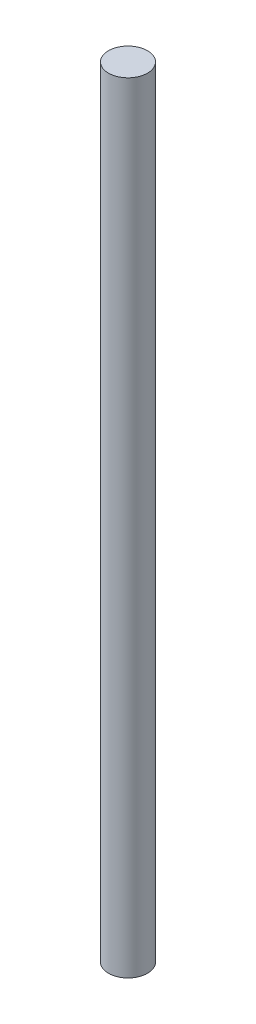
from build123d import *

# Parameters (mm, degrees)
SKETCH1_R           = 3.175
BOSS_EXTRUDE1_DEPTH = 63.5


with BuildPart() as part:
    # Sketch1 → Boss-Extrude1 (new body, symmetric)
    with BuildSketch(Plane(origin=(0, 0, 0), x_dir=(1, 0, 0), z_dir=(0, 1, 0))):
        Circle(SKETCH1_R)
    extrude(amount=BOSS_EXTRUDE1_DEPTH, both=True)


solid = part.part
